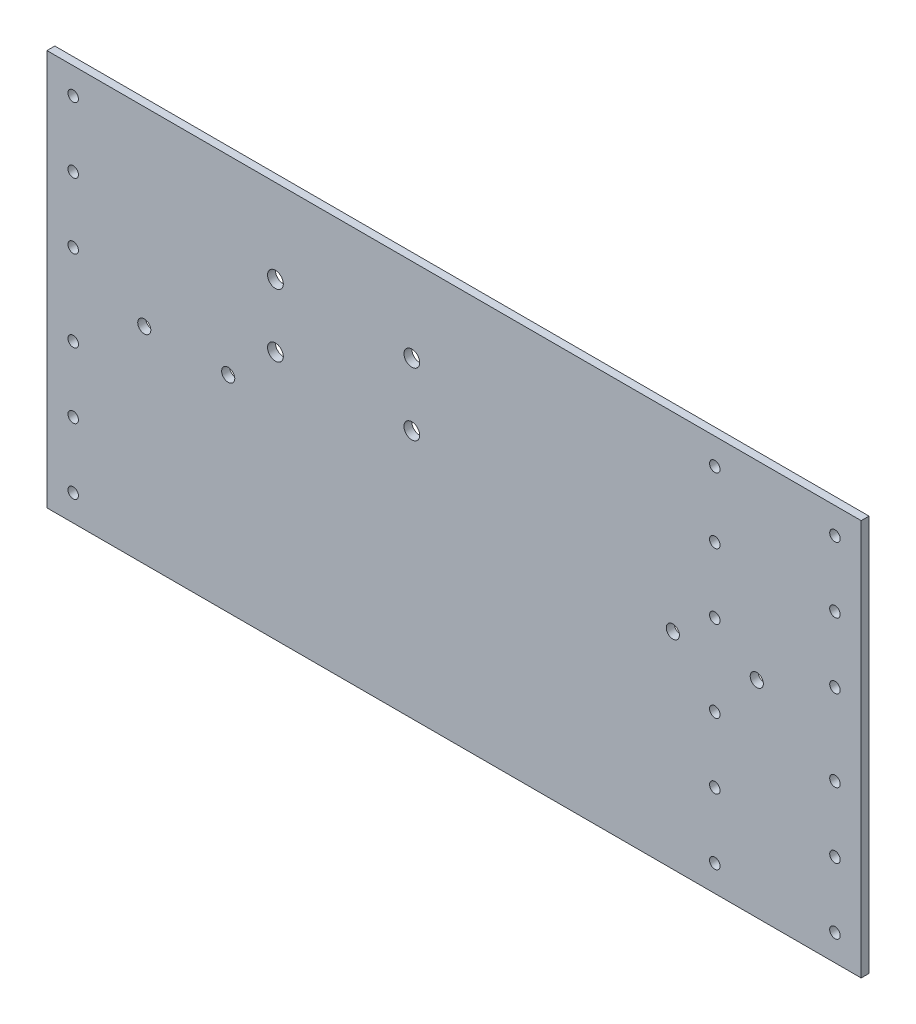
from build123d import *

# Parameters (mm, degrees)
SKIZZE1_W                       = 310.4
SKIZZE1_H                       = 151
AUFSATZ_LINEAR_AUSTRAGEN1_DEPTH = 3
SKIZZE2_R                       = 2
SCHNITT_LINEAR_AUSTRAGEN1_DEPTH = 10
SKIZZE3_R                       = 2
SCHNITT_LINEAR_AUSTRAGEN2_DEPTH = 10
SKIZZE4_R                       = 3
SCHNITT_LINEAR_AUSTRAGEN3_DEPTH = 10
SKIZZE5_R                       = 2.5
SCHNITT_LINEAR_AUSTRAGEN4_DEPTH = 10
SKIZZE6_R                       = 2.5
SCHNITT_LINEAR_AUSTRAGEN5_DEPTH = 10


with BuildPart() as part:
    # Skizze1 → Aufsatz-Linear austragen1 (new body)
    with BuildSketch(Plane.XY):
        with Locations((155.2, 75.5)):
            Rectangle(SKIZZE1_W, SKIZZE1_H)
    extrude(amount=AUFSATZ_LINEAR_AUSTRAGEN1_DEPTH)

    # Skizze2 → Schnitt-Linear austragen1 (cut)
    with BuildSketch(Plane(origin=(0, 0, 0), x_dir=(-1, 0, 0), z_dir=(0, 0, -1))):
        with Locations((-300.4, 116)):
            Circle(SKIZZE2_R)
        with Locations((-300.4, 141)):
            Circle(SKIZZE2_R)
        with Locations((-300.4, 60)):
            Circle(SKIZZE2_R)
        with Locations((-300.4, 91)):
            Circle(SKIZZE2_R)
        with Locations((-300.4, 35)):
            Circle(SKIZZE2_R)
        with Locations((-300.4, 10)):
            Circle(SKIZZE2_R)
        with Locations((-10, 141)):
            Circle(SKIZZE2_R)
        with Locations((-10, 116)):
            Circle(SKIZZE2_R)
        with Locations((-10, 91)):
            Circle(SKIZZE2_R)
        with Locations((-10, 60)):
            Circle(SKIZZE2_R)
        with Locations((-10, 35)):
            Circle(SKIZZE2_R)
        with Locations((-10, 10)):
            Circle(SKIZZE2_R)
    extrude(amount=-SCHNITT_LINEAR_AUSTRAGEN1_DEPTH, mode=Mode.SUBTRACT)

    # Skizze3 → Schnitt-Linear austragen2 (cut)
    with BuildSketch(Plane(origin=(0, 0, 0), x_dir=(-1, 0, 0), z_dir=(0, 0, -1))):
        with Locations((-254.6, 10)):
            Circle(SKIZZE3_R)
        with Locations((-254.6, 35)):
            Circle(SKIZZE3_R)
        with Locations((-254.6, 60)):
            Circle(SKIZZE3_R)
        with Locations((-254.6, 91)):
            Circle(SKIZZE3_R)
        with Locations((-254.6, 116)):
            Circle(SKIZZE3_R)
        with Locations((-254.6, 141)):
            Circle(SKIZZE3_R)
    extrude(amount=-SCHNITT_LINEAR_AUSTRAGEN2_DEPTH, mode=Mode.SUBTRACT)

    # Skizze4 → Schnitt-Linear austragen3 (cut)
    with BuildSketch(Plane(origin=(0, 0, 0), x_dir=(-1, 0, 0), z_dir=(0, 0, -1))):
        with Locations((-139.1, 119)):
            Circle(SKIZZE4_R)
        with Locations((-87.1, 119)):
            Circle(SKIZZE4_R)
        with Locations((-139.1, 95)):
            Circle(SKIZZE4_R)
        with Locations((-87.1, 95)):
            Circle(SKIZZE4_R)
    extrude(amount=-SCHNITT_LINEAR_AUSTRAGEN3_DEPTH, mode=Mode.SUBTRACT)

    # Skizze5 → Schnitt-Linear austragen4 (cut)
    with BuildSketch(Plane(origin=(0, 0, 0), x_dir=(-1, 0, 0), z_dir=(0, 0, -1))):
        with Locations((-270.6, 78.5)):
            Circle(SKIZZE5_R)
        with Locations((-238.6, 78.5)):
            Circle(SKIZZE5_R)
    extrude(amount=-SCHNITT_LINEAR_AUSTRAGEN4_DEPTH, mode=Mode.SUBTRACT)

    # Skizze6 → Schnitt-Linear austragen5 (cut)
    with BuildSketch(Plane(origin=(0, 0, 0), x_dir=(-1, 0, 0), z_dir=(0, 0, -1))):
        with Locations((-69.1, 78.5)):
            Circle(SKIZZE6_R)
        with Locations((-37.1, 78.5)):
            Circle(SKIZZE6_R)
    extrude(amount=-SCHNITT_LINEAR_AUSTRAGEN5_DEPTH, mode=Mode.SUBTRACT)


solid = part.part
